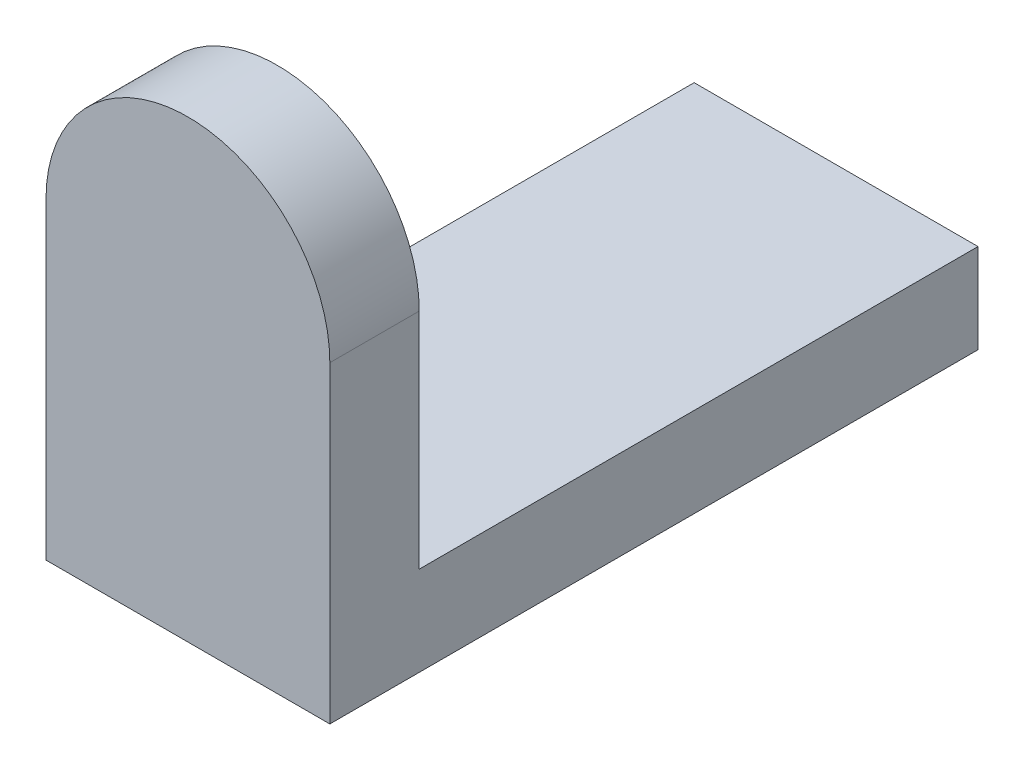
from build123d import *

# Parameters (mm, degrees)
SKETCH1_W           = 25.4
SKETCH1_H           = 50
BOSS_EXTRUDE2_DEPTH = 8
BOSS_EXTRUDE4_DEPTH = 8


with BuildPart() as part:
    # Sketch1 → Boss-Extrude2 (new body)
    with BuildSketch(Plane(origin=(0, 0, 0), x_dir=(1, 0, 0), z_dir=(0, 1, 0))):
        Rectangle(SKETCH1_W, SKETCH1_H)
    extrude(amount=BOSS_EXTRUDE2_DEPTH)

    # Sketch4 → Boss-Extrude4 (add)
    with BuildSketch(Plane.XY.offset(25)):
        with BuildLine():
            Line((-12.7, 0), (12.7, 0))
            Line((12.7, 0), (12.7, 28))
            ThreePointArc((12.7, 28), (0, 40.7), (-12.7, 28))
            Line((-12.7, 28), (-12.7, 0))
        make_face()
    extrude(amount=BOSS_EXTRUDE4_DEPTH)


solid = part.part
